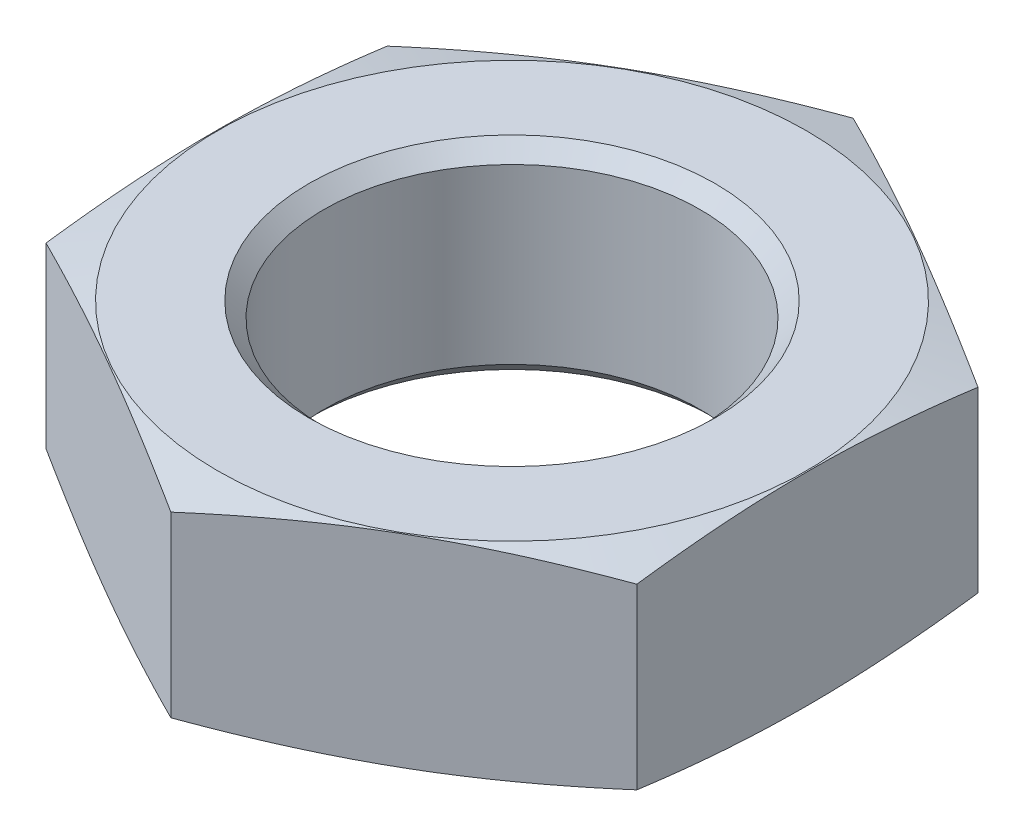
from build123d import *

# Parameters (mm, degrees)
SKETCH2_W               = 128
SKETCH2_H               = 128
CUT_EXTRUDE1_DEPTH      = 12
CUT_EXTRUDE1_DEPTH_BACK = 12


with BuildPart() as part:
    # Sketch1 → Revolve1 (revolve)
    with BuildSketch(Plane.XY):
        Polygon((0, 0), (15.95, 0), (36.476279442, -5.5), (15.95, -11), (0, -11), align=None)
    revolve(axis=Axis((0, -11, 0), (0, 1, 0)))

    # Sketch2 → Cut-Extrude1 (cut, two sides)
    with BuildSketch(Plane(origin=(0, 0, 0), x_dir=(1, 0, 0), z_dir=(0, 1, 0))) as cut_extrude1_sk:
        Rectangle(SKETCH2_W, SKETCH2_H)
        Polygon((-16, -9.237604307), (0, -18.475208614), (16, -9.237604307), (16, 9.237604307), (0, 18.475208614), (-16, 9.237604307), align=None, mode=Mode.SUBTRACT)
    extrude(amount=CUT_EXTRUDE1_DEPTH, mode=Mode.SUBTRACT)
    extrude(cut_extrude1_sk.sketch, amount=-CUT_EXTRUDE1_DEPTH_BACK, mode=Mode.SUBTRACT)

    # Sketch3 → Cut-Revolve1 (revolve, cut)
    with BuildSketch(Plane.XY):
        Polygon((0, 0), (11, 0), (10.188, -0.812), (10.188, -10.188), (11, -11), (0, -11), align=None)
    revolve(axis=Axis((0, -11, 0), (0, 1, 0)), mode=Mode.SUBTRACT)


solid = part.part
